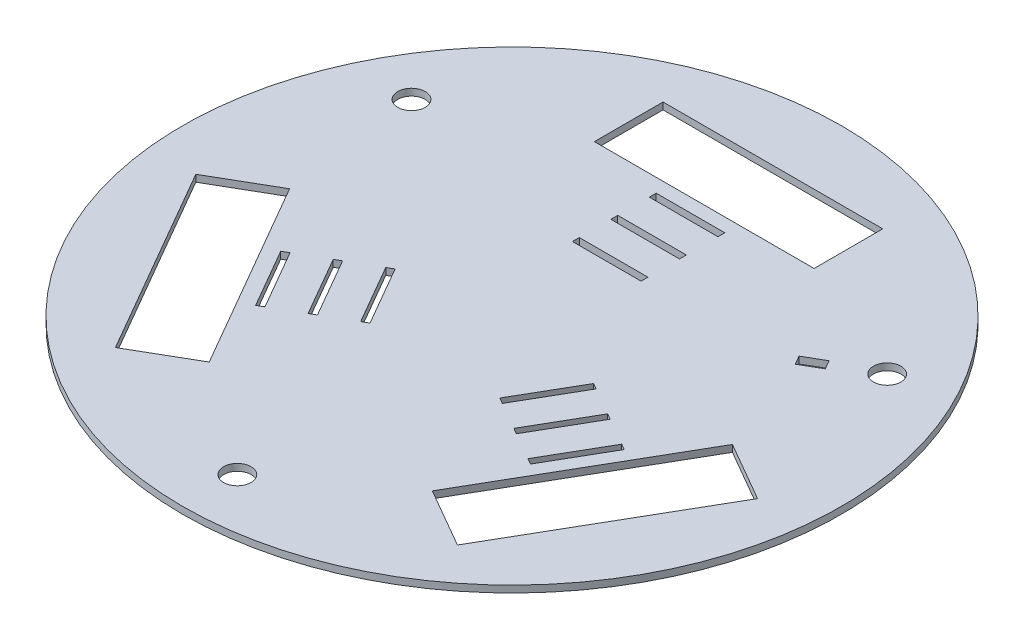
from build123d import *

# Parameters (mm, degrees)
SKETCH1_R           = 152.4
BOSS_EXTRUDE1_DEPTH = 3.175
SKETCH2_R           = 6.35
SKETCH2_W           = 101.6
SKETCH2_H           = 31.75
SKETCH2_W_2         = 31.75
SKETCH2_H_2         = 3.175
CUT_EXTRUDE1_DEPTH  = 3.175


with BuildPart() as part:
    # Sketch1 → Boss-Extrude1 (new body)
    with BuildSketch(Plane(origin=(0, 0, 0), x_dir=(1, 0, 0), z_dir=(0, 1, 0))):
        with Locations(Location((152.4, 152.4, 0), (0, 0, 270))):  # turned: the seam where the file's is
            Circle(SKETCH1_R)
    extrude(amount=BOSS_EXTRUDE1_DEPTH)

    # Sketch2 → Cut-Extrude1 (cut)
    with BuildSketch(Plane(origin=(0, 3.175, 0), x_dir=(1, 0, 0), z_dir=(0, 1, 0))):
        with Locations(Location((152.4, 25.4, 0), (0, 0, 270))):  # turned: the seam where the file's is
            Circle(SKETCH2_R)
        with Locations(Location((42.414773719, 215.9, 0), (0, 0, 270))):  # turned: the seam where the file's is
            Circle(SKETCH2_R)
        with Locations(Location((262.385226281, 215.9, 0), (0, 0, 270))):  # turned: the seam where the file's is
            Circle(SKETCH2_R)
        Polygon((282.285964967, 136.069090512), (231.485964967, 48.080909488), (203.989658396, 63.955909488), (254.789658396, 151.944090512), align=None)
        Polygon((231.827897082, 124.873153285), (215.952897082, 97.376846715), (213.203266425, 98.964346715), (229.078266425, 126.460653285), align=None)
        Polygon((216.429965403, 133.763153285), (200.554965403, 106.266846715), (197.805334746, 107.854346715), (213.680334746, 135.350653285), align=None)
        Polygon((73.314035033, 48.080909488), (22.514035033, 136.069090512), (50.010341604, 151.944090512), (100.810341604, 63.955909488), align=None)
        with Locations((152.4, 257.175)):
            Rectangle(SKETCH2_W, SKETCH2_H)
        Polygon((88.847102918, 97.376846715), (72.972102918, 124.873153285), (75.721733575, 126.460653285), (91.596733575, 98.964346715), align=None)
        Polygon((104.245034597, 106.266846715), (88.370034597, 133.763153285), (91.119665254, 135.350653285), (106.994665254, 107.854346715), align=None)
        with Locations((152.4, 233.3625)):
            Rectangle(SKETCH2_W_2, SKETCH2_H_2)
        with Locations((152.4, 215.5825)):
            Rectangle(SKETCH2_W_2, SKETCH2_H_2)
        Polygon((119.642966276, 115.156846715), (103.767966276, 142.653153285), (106.517596933, 144.240653285), (122.392596933, 116.744346715), align=None)
        Polygon((243.596965076, 207.802222993), (245.978215076, 203.677777007), (237.179396973, 198.597777007), (234.798146973, 202.722222993), align=None)
        Polygon((201.032033724, 142.653153285), (185.157033724, 115.156846715), (182.407403067, 116.744346715), (198.282403067, 144.240653285), align=None)
        with Locations((152.4, 197.8025)):
            Rectangle(SKETCH2_W_2, SKETCH2_H_2)
    extrude(amount=-CUT_EXTRUDE1_DEPTH, mode=Mode.SUBTRACT)


solid = part.part
